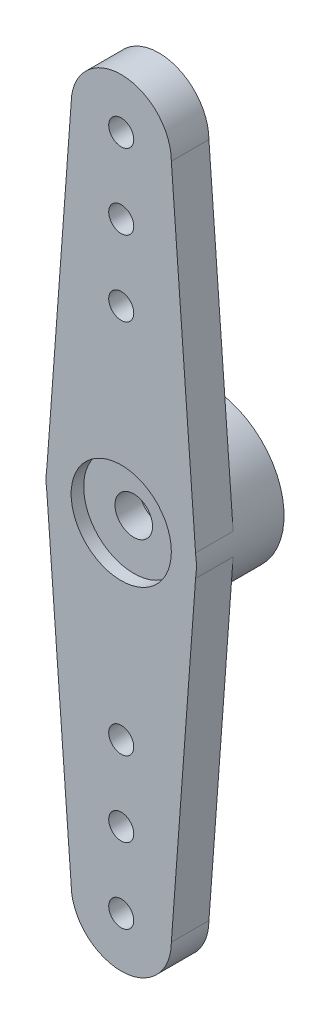
from build123d import *

# Parameters (mm, degrees)
BOSS_EXTRU_2_DEPTH         = 1.5
ESQUISSE2_R                = 3
ESQUISSE2_R_2              = 2
BOSS_EXTRU_3_DEPTH         = 2
ESQUISSE3_R                = 0.75
ENL_V_MAT_EXTRU_1_DEPTH    = 2
ESQUISSE4_R                = 2
ENL_V_MAT_EXTRU_2_DEPTH    = 0.5
ESQUISSE5_R                = 0.5
ENL_V_MAT_EXTRU_3_DEPTH    = 4.5
R_P_TITION_LIN_AIRE1_COUNT = 3
R_P_TITION_LIN_AIRE1_PITCH = 3
SYM_TRIE1_COPY_1_SKETCH_R  = 0.5
SYM_TRIE1_COPY_1_DEPTH     = 4.5
SYM_TRIE1_COPY_2_SKETCH_R  = 0.5
SYM_TRIE1_COPY_2_DEPTH     = 4.5


with BuildPart() as part:
    # Esquisse1 → Boss.-Extru.2 (new body)
    with BuildSketch(Plane.XY):
        with BuildLine():
            Line((2, 13.5), (2.967257844, 0.4420191))
            ThreePointArc((2.967257844, 0.4420191), (3, 0), (2.967257844, -0.4420191))
            Line((2.967257844, -0.4420191), (2, -13.5))
            ThreePointArc((2, -13.5), (0, -15.5), (-2, -13.5))
            Line((-2, -13.5), (-2.967257844, -0.4420191))
            ThreePointArc((-2.967257844, -0.4420191), (-3, 0), (-2.967257844, 0.4420191))
            Line((-2.967257844, 0.4420191), (-2, 13.5))
            ThreePointArc((-2, 13.5), (0, 15.5), (2, 13.5))
        make_face()
    extrude(amount=BOSS_EXTRU_2_DEPTH)

    # Esquisse2 → Boss.-Extru.3 (add)
    with BuildSketch(Plane(origin=(0, 0, 0), x_dir=(-1, 0, 0), z_dir=(0, 0, -1))):
        Circle(ESQUISSE2_R)
        Circle(ESQUISSE2_R_2, mode=Mode.SUBTRACT)
    extrude(amount=BOSS_EXTRU_3_DEPTH)

    # Esquisse3 → Enlèv. mat.-Extru.1 (cut)
    with BuildSketch(Plane(origin=(0, 0, 0), x_dir=(-1, 0, 0), z_dir=(0, 0, -1))):
        Circle(ESQUISSE3_R)
    extrude(amount=-ENL_V_MAT_EXTRU_1_DEPTH, mode=Mode.SUBTRACT)

    # Esquisse4 → Enlèv. mat.-Extru.2 (cut)
    with BuildSketch(Plane.XY.offset(1.5)):
        Circle(ESQUISSE4_R)
    extrude(amount=-ENL_V_MAT_EXTRU_2_DEPTH, mode=Mode.SUBTRACT)

    # Esquisse5 → Enlèv. mat.-Extru.3 (cut, through all)
    with BuildSketch(Plane.XY.offset(1.5)):
        with Locations((0, 13.5)):
            Circle(ESQUISSE5_R)
    enl_v_mat_extru_3 = extrude(amount=-ENL_V_MAT_EXTRU_3_DEPTH, mode=Mode.SUBTRACT)

    # Répétition linéaire1: Enlèv. mat.-Extru.3 ×3
    with Locations(*[(0, -i * R_P_TITION_LIN_AIRE1_PITCH, 0) for i in range(1, R_P_TITION_LIN_AIRE1_COUNT)]):
        add(enl_v_mat_extru_3, mode=Mode.SUBTRACT)

    # Symétrie1: Enlèv. mat.-Extru.3 across plane
    add(enl_v_mat_extru_3.mirror(Plane.ZX), mode=Mode.SUBTRACT)

    # Symétrie1 copy 1 sketch → Symétrie1 copy 1 (cut, through all)
    with BuildSketch(Plane(origin=(0, 3, 1.5), x_dir=(1, 0, 0), z_dir=(0, 0, 1))):
        with Locations((0, -13.5)):
            Circle(SYM_TRIE1_COPY_1_SKETCH_R)
    extrude(amount=-SYM_TRIE1_COPY_1_DEPTH, mode=Mode.SUBTRACT)

    # Symétrie1 copy 2 sketch → Symétrie1 copy 2 (cut, through all)
    with BuildSketch(Plane(origin=(0, 6, 1.5), x_dir=(1, 0, 0), z_dir=(0, 0, 1))):
        with Locations((0, -13.5)):
            Circle(SYM_TRIE1_COPY_2_SKETCH_R)
    extrude(amount=-SYM_TRIE1_COPY_2_DEPTH, mode=Mode.SUBTRACT)


solid = part.part
